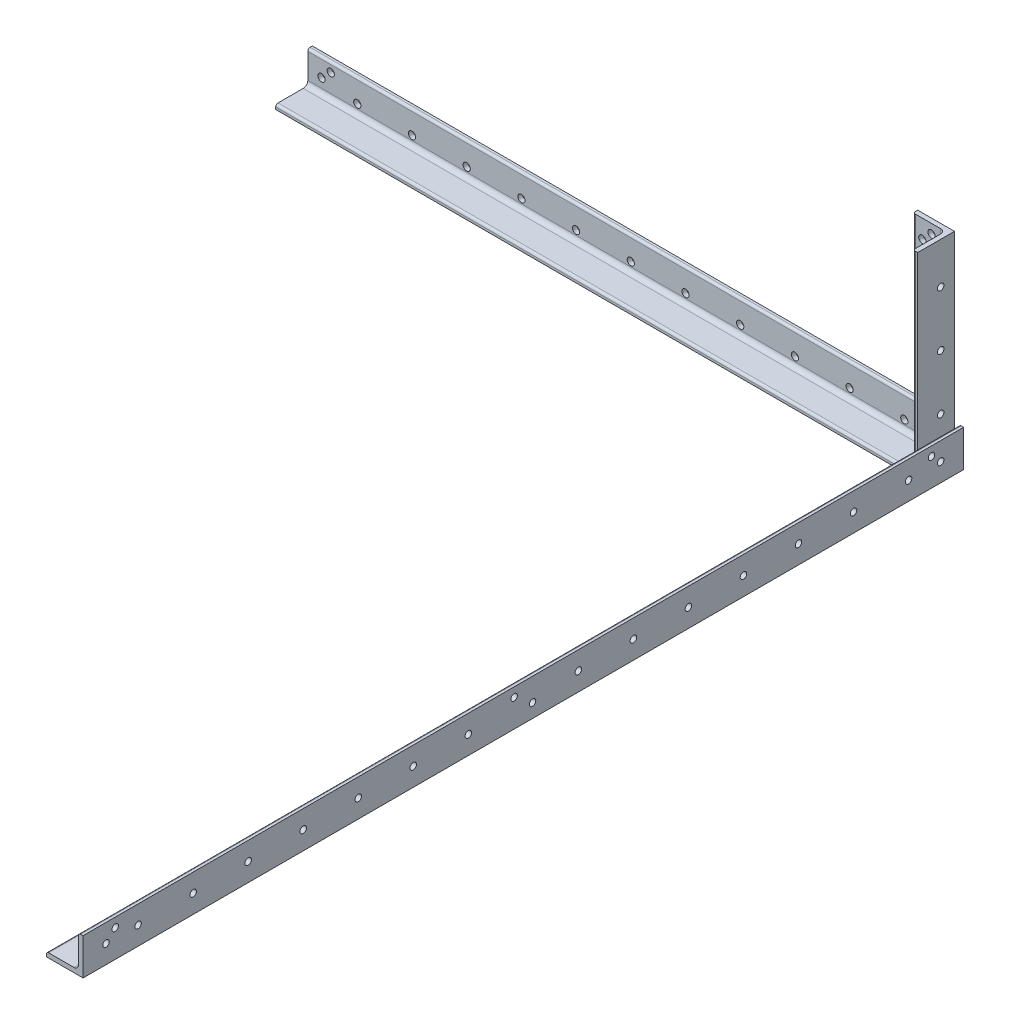
from build123d import *

# Parameters (mm, degrees)
BOSS_EXTRUDE1_DEPTH = 304.8
SKETCH3_W           = 444.5
SKETCH3_H           = 25.4
BOSS_EXTRUDE2_DEPTH = 3.175
SKETCH4_W           = 25.4
SKETCH4_H           = 3.175
BOSS_EXTRUDE3_DEPTH = 444.5
FILLET1_R           = 1.5875
FILLET2_R           = 3.175
SKETCH6_W           = 25.4
SKETCH6_H           = 3.175
BOSS_EXTRUDE4_DEPTH = 25.4
SKETCH7_W           = 22.225
SKETCH7_H           = 22.225
CUT_EXTRUDE1_DEPTH  = 3.175
BOSS_EXTRUDE5_DEPTH = 130.175
FILLET3_R           = 1.5875
FILLET4_R           = 3.175
SKETCH10_R          = 2.25
CUT_EXTRUDE2_DEPTH  = 50.8
SKETCH11_R          = 2.5
CUT_EXTRUDE3_DEPTH  = 50.8
SKETCH12_R          = 2.25
CUT_EXTRUDE4_DEPTH  = 50.8
SKETCH13_R          = 2.5
CUT_EXTRUDE5_DEPTH  = 50.8
SKETCH14_R          = 2.5
CUT_EXTRUDE6_DEPTH  = 50.8
SKETCH18_R          = 2.25
CUT_EXTRUDE7_DEPTH  = 25.4


with BuildPart() as part:
    # Sketch2 → Boss-Extrude1 (new, symmetric)
    with BuildSketch(Plane.XY):
        with BuildLine():
            Line((-12.7, -12.7), (12.7, -12.7))
            Line((12.7, -12.7), (12.7, 12.7))
            Line((12.7, 12.7), (11.1125, 12.7))
            ThreePointArc((11.1125, 12.7), (9.989967985, 12.235032015), (9.525, 11.1125))
            Line((9.525, 11.1125), (9.525, -6.35))
            ThreePointArc((9.525, -6.35), (8.59506403, -8.59506403), (6.35, -9.525))
            Line((6.35, -9.525), (-11.1125, -9.525))
            ThreePointArc((-11.1125, -9.525), (-12.235032015, -9.989967985), (-12.7, -11.1125))
            Line((-12.7, -11.1125), (-12.7, -12.7))
        make_face()
    extrude(amount=BOSS_EXTRUDE1_DEPTH, both=True)


with BuildPart() as body_2:
    # Sketch3 → Boss-Extrude2 (new body)
    with BuildSketch(Plane(origin=(0, 0, -304.8), x_dir=(-1, 0, 0), z_dir=(0, 0, -1))):
        with Locations((215.9, 3.175)):
            Rectangle(SKETCH3_W, SKETCH3_H)
    extrude(amount=-BOSS_EXTRUDE2_DEPTH)

    # Sketch4 → Boss-Extrude3 (add)
    with BuildSketch(Plane.ZY.offset(438.15)):
        with Locations((-292.1, -7.9375)):
            Rectangle(SKETCH4_W, SKETCH4_H)
    extrude(amount=-BOSS_EXTRUDE3_DEPTH)

    # Fillet1
    fillet1_edges = [body_2.edges().sort_by_distance(p)[0] for p in [
        (-215.9, 15.875, -301.625),
        (-215.9, -6.35, -279.4),
    ]]
    fillet(fillet1_edges, radius=FILLET1_R)

    # Fillet2
    fillet2_edges = [body_2.edges().sort_by_distance(p)[0] for p in [
        (-215.9, -6.35, -301.625),
    ]]
    fillet(fillet2_edges, radius=FILLET2_R)


with BuildPart() as body_3:
    # Sketch6 → Boss-Extrude4 (new body)
    with BuildSketch(Plane.ZY.offset(-9.525)):
        with Locations((-288.925, -1.5875)):
            Rectangle(SKETCH6_W, SKETCH6_H)
    extrude(amount=BOSS_EXTRUDE4_DEPTH)

    # Sketch7 → Cut-Extrude1 (cut)
    with BuildSketch(Plane(origin=(0, 0, 0), x_dir=(1, 0, 0), z_dir=(0, 1, 0))):
        with Locations((-4.7625, 287.3375)):
            Rectangle(SKETCH7_W, SKETCH7_H)
    extrude(amount=-CUT_EXTRUDE1_DEPTH, mode=Mode.SUBTRACT)

    # Sketch8 → Boss-Extrude5 (add)
    with BuildSketch(Plane(origin=(0, 0, 0), x_dir=(1, 0, 0), z_dir=(0, 1, 0))):
        Polygon((-15.875, 301.625), (-15.875, 298.45), (6.35, 298.45), (6.35, 276.225), (9.525, 276.225), (9.525, 301.625), align=None)
    extrude(amount=BOSS_EXTRUDE5_DEPTH)

    # Fillet3
    fillet3_edges = [body_3.edges().sort_by_distance(p)[0] for p in [
        (-15.875, 63.5, -298.45),
        (6.35, 63.5, -276.225),
    ]]
    fillet(fillet3_edges, radius=FILLET3_R)

    # Fillet4
    fillet4_edges = [body_3.edges().sort_by_distance(p)[0] for p in [
        (6.35, 63.5, -298.45),
    ]]
    fillet(fillet4_edges, radius=FILLET4_R)


with BuildPart() as cut_extrude2_tool:
    # Sketch10 → Cut-Extrude2 (new body)
    with BuildSketch(Plane(origin=(12.7, 0, 0), x_dir=(0, 0, -1), z_dir=(1, 0, 0))):
        with Locations(Location((282.575, 6.35, 0), (0, 0, 90))):
            Circle(SKETCH10_R)
        with Locations(Location((288.925, 0, 0), (0, 0, 90))):
            Circle(SKETCH10_R)
    extrude(amount=-CUT_EXTRUDE2_DEPTH)


with BuildPart() as part_1:
    add(part.part)

    # Cut-Extrude2: cut by cut_extrude2_tool
    add(cut_extrude2_tool.part, mode=Mode.SUBTRACT)

    # Sketch12 → Cut-Extrude4 (cut)
    with BuildSketch(Plane(origin=(12.7, 0, 0), x_dir=(0, 0, -1), z_dir=(1, 0, 0))):
        with Locations(Location((288.925, 0, 0), (0, 0, 90))):
            Circle(SKETCH12_R)
        with Locations(Location((282.575, 6.35, 0), (0, 0, 90))):
            Circle(SKETCH12_R)
        with Locations(Location((-288.925, 0, 0), (0, 0, 90))):
            Circle(SKETCH12_R)
        with Locations(Location((-282.575, 6.35, 0), (0, 0, 90))):
            Circle(SKETCH12_R)
        with Locations(Location((-6.35, 6.35, 0), (0, 0, 90))):
            Circle(SKETCH12_R)
        with Locations(Location((6.35, -3.175, 0), (0, 0, 90))):
            Circle(SKETCH12_R)
        with Locations(Location((-266.7, 0, 0), (0, 0, 90))):
            Circle(SKETCH12_R)
        with Locations(Location((-228.6, 0, 0), (0, 0, 90))):
            Circle(SKETCH12_R)
        with Locations(Location((-190.5, 0, 0), (0, 0, 90))):
            Circle(SKETCH12_R)
        with Locations(Location((-152.4, 0, 0), (0, 0, 90))):
            Circle(SKETCH12_R)
        with Locations(Location((-114.3, 0, 0), (0, 0, 90))):
            Circle(SKETCH12_R)
        with Locations(Location((-76.2, 0, 0), (0, 0, 90))):
            Circle(SKETCH12_R)
        with Locations(Location((-38.1, 0, 0), (0, 0, 90))):
            Circle(SKETCH12_R)
        with Locations(Location((38.1, 0, 0), (0, 0, 90))):
            Circle(SKETCH12_R)
        with Locations(Location((76.2, 0, 0), (0, 0, 90))):
            Circle(SKETCH12_R)
        with Locations(Location((114.3, 0, 0), (0, 0, 90))):
            Circle(SKETCH12_R)
        with Locations(Location((152.4, 0, 0), (0, 0, 90))):
            Circle(SKETCH12_R)
        with Locations(Location((190.5, 0, 0), (0, 0, 90))):
            Circle(SKETCH12_R)
        with Locations(Location((228.6, 0, 0), (0, 0, 90))):
            Circle(SKETCH12_R)
        with Locations(Location((266.7, 0, 0), (0, 0, 90))):
            Circle(SKETCH12_R)
    extrude(amount=-CUT_EXTRUDE4_DEPTH, mode=Mode.SUBTRACT)


with BuildPart() as body_3_1:
    add(body_3.part)

    # Cut-Extrude2: cut by cut_extrude2_tool
    add(cut_extrude2_tool.part, mode=Mode.SUBTRACT)


with BuildPart() as cut_extrude3_tool:
    # Sketch11 → Cut-Extrude3 (new body)
    with BuildSketch(Plane(origin=(0, 0, -304.8), x_dir=(-1, 0, 0), z_dir=(0, 0, -1))):
        with Locations((3.175, 3.175)):
            Circle(SKETCH11_R)
        with Locations((9.525, 9.525)):
            Circle(SKETCH11_R)
    extrude(amount=-CUT_EXTRUDE3_DEPTH)


with BuildPart() as body_2_1:
    add(body_2.part)

    # Cut-Extrude3: cut by cut_extrude3_tool
    add(cut_extrude3_tool.part, mode=Mode.SUBTRACT)

    # Sketch13 → Cut-Extrude5 (cut)
    with BuildSketch(Plane(origin=(0, 0, -304.8), x_dir=(-1, 0, 0), z_dir=(0, 0, -1))):
        with Locations((25.172045256, 0)):
            Circle(SKETCH13_R)
        with Locations((63.044090512, 0)):
            Circle(SKETCH13_R)
        with Locations((100.916135768, 0)):
            Circle(SKETCH13_R)
        with Locations((138.788181024, 0)):
            Circle(SKETCH13_R)
        with Locations((176.660226281, 0)):
            Circle(SKETCH13_R)
        with Locations((214.532271537, 0)):
            Circle(SKETCH13_R)
        with Locations((252.404316793, 0)):
            Circle(SKETCH13_R)
        with Locations((290.276362049, 0)):
            Circle(SKETCH13_R)
        with Locations((328.148407305, 0)):
            Circle(SKETCH13_R)
        with Locations((366.020452561, 0)):
            Circle(SKETCH13_R)
        with Locations((403.892497817, 0)):
            Circle(SKETCH13_R)
        with Locations((3.175, 3.175)):
            Circle(SKETCH13_R)
        with Locations((9.525, 9.525)):
            Circle(SKETCH13_R)
        with Locations(Location((428.625, 3.175, 0), (0, 0, 180))):
            Circle(SKETCH13_R)
        with Locations(Location((422.275, 9.525, 0), (0, 0, 180))):
            Circle(SKETCH13_R)
    extrude(amount=-CUT_EXTRUDE5_DEPTH, mode=Mode.SUBTRACT)


with BuildPart() as body_3_2:
    add(body_3_1.part)

    # Cut-Extrude3: cut by cut_extrude3_tool
    add(cut_extrude3_tool.part, mode=Mode.SUBTRACT)

    # Sketch14 → Cut-Extrude6 (cut)
    with BuildSketch(Plane(origin=(0, 0, -304.8), x_dir=(-1, 0, 0), z_dir=(0, 0, -1))):
        with Locations((0, 25.4)):
            Circle(SKETCH14_R)
        with Locations((0, 63.5)):
            Circle(SKETCH14_R)
        with Locations((0, 101.6)):
            Circle(SKETCH14_R)
        with Locations((0, 139.7)):
            Circle(SKETCH14_R)
        with Locations((3.175, 3.175)):
            Circle(SKETCH14_R)
        with Locations((9.525, 9.525)):
            Circle(SKETCH14_R)
        with Locations((3.175, 123.825)):
            Circle(SKETCH14_R)
        with Locations((9.525, 117.475)):
            Circle(SKETCH14_R)
    extrude(amount=-CUT_EXTRUDE6_DEPTH, mode=Mode.SUBTRACT)

    # Sketch18 → Cut-Extrude7 (cut)
    with BuildSketch(Plane(origin=(9.525, 0, 0), x_dir=(0, 0, -1), z_dir=(1, 0, 0))):
        with Locations((292.1, 25.4)):
            Circle(SKETCH18_R)
        with Locations((292.1, 63.5)):
            Circle(SKETCH18_R)
        with Locations((292.1, 101.6)):
            Circle(SKETCH18_R)
    extrude(amount=-CUT_EXTRUDE7_DEPTH, mode=Mode.SUBTRACT)


solid = Compound([part_1.part, body_2_1.part, body_3_2.part])
